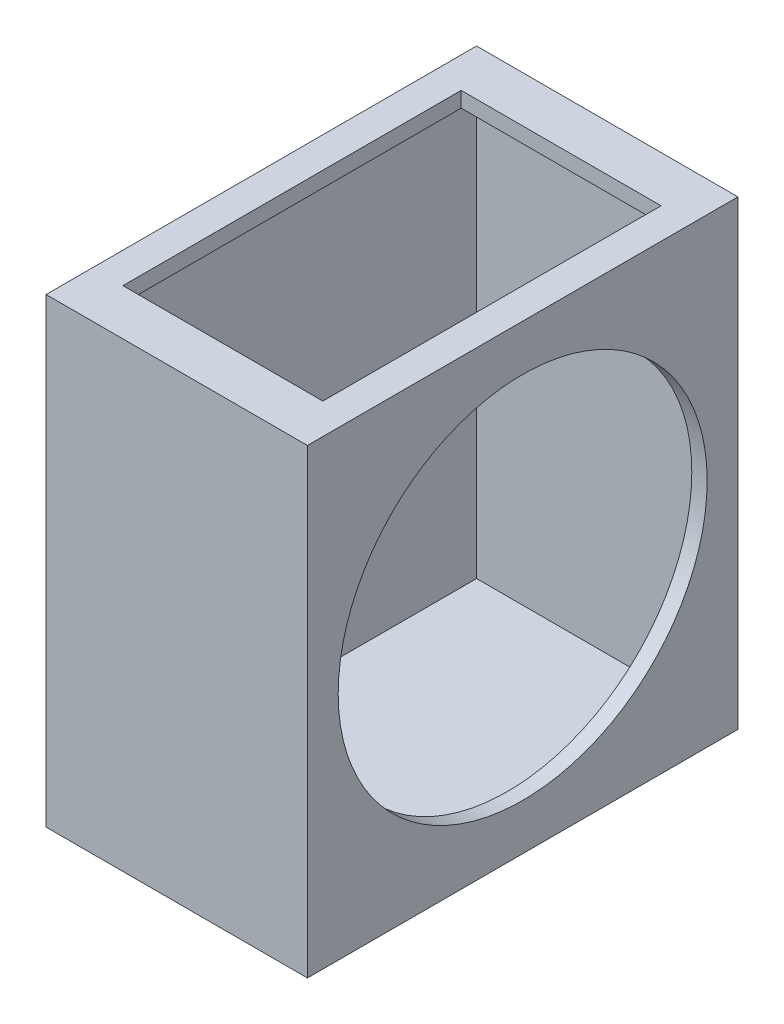
from build123d import *

# Parameters (mm, degrees)
SKETCH1_W           = 8.5
SKETCH1_H           = 15
BOSS_EXTRUDE1_DEPTH = 14
SHELL3_T            = -0.5
SKETCH2_W           = 14
SKETCH2_H           = 15
SKETCH2_R           = 6
BOSS_EXTRUDE2_DEPTH = 0.5
SKETCH3_W           = 6.5
SKETCH3_H           = 11
CUT_EXTRUDE1_DEPTH  = 0.5
SCALE1_SCALE        = 10


with BuildPart() as part:
    # Sketch1 → Boss-Extrude1 (new body)
    with BuildSketch(Plane.XY):
        Rectangle(SKETCH1_W, SKETCH1_H)
    extrude(amount=BOSS_EXTRUDE1_DEPTH)

    # Shell3
    shell3_openings = [part.faces().sort_by_distance(p)[0] for p in [
        (4.25, 0, 7),
    ]]
    offset(amount=SHELL3_T, openings=shell3_openings, kind=Kind.INTERSECTION)

    # Sketch2 → Boss-Extrude2 (add)
    with BuildSketch(Plane(origin=(4.25, 0, 0), x_dir=(0, 0, -1), z_dir=(1, 0, 0))):
        with Locations((-7, 0)):
            Rectangle(SKETCH2_W, SKETCH2_H)
        with Locations((-7, 0)):
            Circle(SKETCH2_R, mode=Mode.SUBTRACT)
    extrude(amount=-BOSS_EXTRUDE2_DEPTH)

    # Sketch3 → Cut-Extrude1 (cut)
    with BuildSketch(Plane(origin=(0, 7.5, 0), x_dir=(1, 0, 0), z_dir=(0, 1, 0))):
        with Locations((0, -7)):
            Rectangle(SKETCH3_W, SKETCH3_H)
    extrude(amount=-CUT_EXTRUDE1_DEPTH, mode=Mode.SUBTRACT)


with BuildPart() as part_1:
    # Scale1: scaled about (-0.690246419, -0.790925988, 7)
    add(part.part.scale(SCALE1_SCALE).moved(Location((6.212217771, 7.118333892, -63))))


solid = part_1.part
